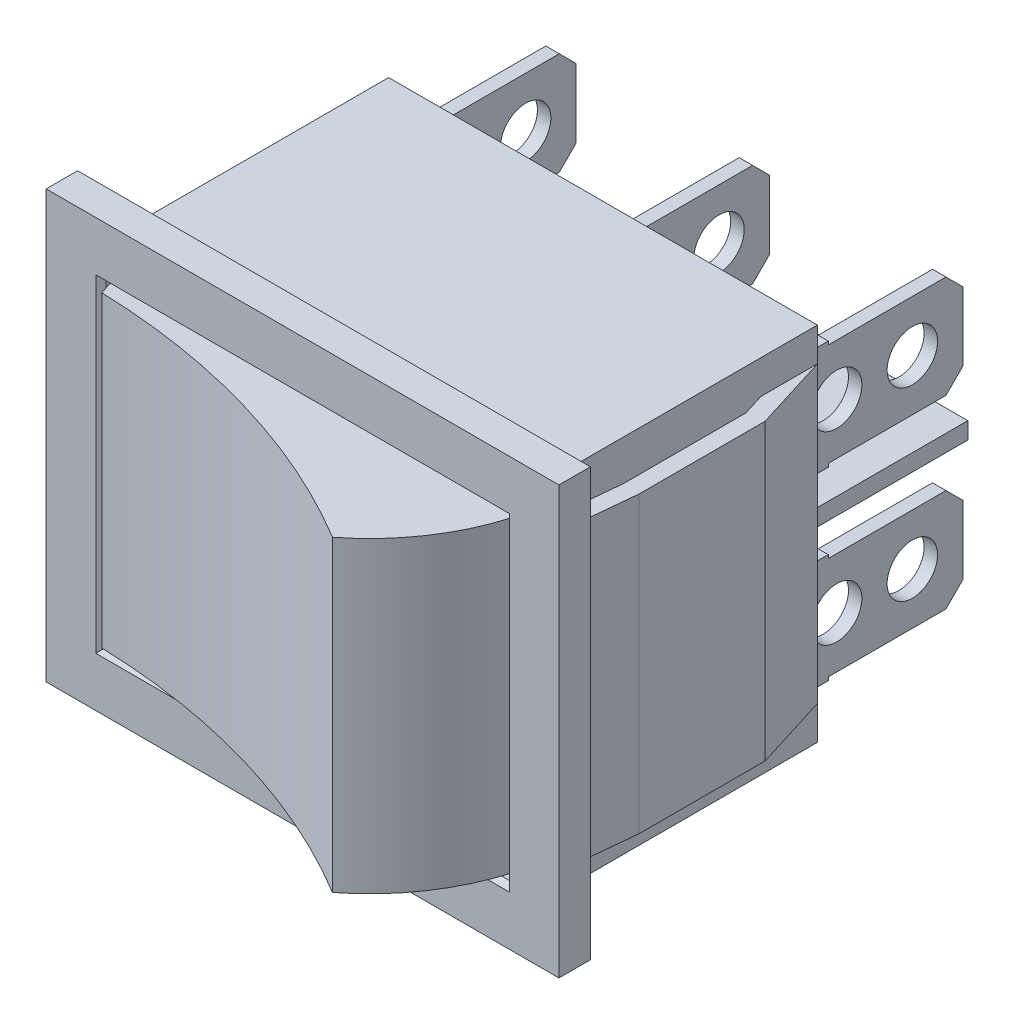
from build123d import *

# Parameters (mm, degrees)
SKETCH1_W                = 25.5
SKETCH1_H                = 21.5
BOSS_EXTRUDE1_DEPTH      = 16
SKETCH3_W                = 30.5
SKETCH3_H                = 25.4
BOSS_EXTRUDE3_DEPTH      = 1.87
SKETCH4_W                = 23.8
SKETCH4_H                = 1
BOSS_EXTRUDE4_DEPTH      = 9.8
SKETCH5_W                = 0.8
SKETCH5_H                = 6.5
BOSS_EXTRUDE5_DEPTH      = 9.5
SKETCH6_W                = 8
SKETCH6_H                = 0.2
CUT_EXTRUDE1_DEPTH       = 28.15
CHAMFER1_SIZE            = 1
SKETCH7_R                = 1.5
CUT_EXTRUDE2_DEPTH       = 28.15
CHAMFER1_OF_MIRROR1_SIZE = 1
BOSS_EXTRUDE6_START      = -2
BOSS_EXTRUDE6_DEPTH      = 17.5
SKETCH9_W                = 24
SKETCH9_H                = 18.9
CUT_EXTRUDE3_DEPTH       = 5
SKETCH10_R               = 12.5
BOSS_EXTRUDE7_DEPTH      = 9.15
SKETCH11_R               = 40
CUT_EXTRUDE4_DEPTH       = 13.7
CUT_EXTRUDE4_DEPTH_BACK  = 13.7
CHAMFER2_SIZE            = 0.3


with BuildPart() as part:
    # Sketch1 → Boss-Extrude1 (new body)
    with BuildSketch(Plane.XY):
        Rectangle(SKETCH1_W, SKETCH1_H)
    extrude(amount=BOSS_EXTRUDE1_DEPTH)

    # Sketch3 → Boss-Extrude3 (add)
    with BuildSketch(Plane.XY.offset(16)):
        Rectangle(SKETCH3_W, SKETCH3_H)
    extrude(amount=BOSS_EXTRUDE3_DEPTH)

    # Sketch4 → Boss-Extrude4 (add)
    with BuildSketch(Plane(origin=(0, 0, 0), x_dir=(-1, 0, 0), z_dir=(0, 0, -1))):
        Rectangle(SKETCH4_W, SKETCH4_H)
    extrude(amount=BOSS_EXTRUDE4_DEPTH)

    # Sketch5 → Boss-Extrude5 (add)
    with BuildSketch(Plane(origin=(0, 0, 0), x_dir=(-1, 0, 0), z_dir=(0, 0, -1))):
        with Locations((11.5, -5.5)):
            Rectangle(SKETCH5_W, SKETCH5_H)
        with Locations((0, -5.5)):
            Rectangle(SKETCH5_W, SKETCH5_H)
        with Locations((-11.5, -5.5)):
            Rectangle(SKETCH5_W, SKETCH5_H)
    boss_extrude5 = extrude(amount=BOSS_EXTRUDE5_DEPTH)

    # Sketch6 → Cut-Extrude1 (cut, through all)
    with BuildSketch(Plane(origin=(11.9, 0, 0), x_dir=(0, 0, -1), z_dir=(1, 0, 0))):
        with Locations((5.5, -2.35)):
            Rectangle(SKETCH6_W, SKETCH6_H)
        with Locations((5.5, -8.65)):
            Rectangle(SKETCH6_W, SKETCH6_H)
    cut_extrude1 = extrude(amount=-CUT_EXTRUDE1_DEPTH, mode=Mode.SUBTRACT)

    # Chamfer1
    chamfer1_edges = [part.edges().sort_by_distance(p)[0] for p in [
        (-11.5, -2.45, -9.5),
        (0, -2.45, -9.5),
        (-11.5, -8.55, -9.5),
        (0, -8.55, -9.5),
        (11.5, -8.55, -9.5),
        (11.5, -2.45, -9.5),
    ]]
    chamfer(chamfer1_edges, length=CHAMFER1_SIZE)

    # Sketch7 → Cut-Extrude2 (cut, through all)
    with BuildSketch(Plane(origin=(11.9, 0, 0), x_dir=(0, 0, -1), z_dir=(1, 0, 0))):
        with Locations((6.5, -5.5)):
            Circle(SKETCH7_R)
        with Locations((2, -5.5)):
            Circle(SKETCH7_R)
    cut_extrude2 = extrude(amount=-CUT_EXTRUDE2_DEPTH, mode=Mode.SUBTRACT)

    # Mirror1: Boss-Extrude5, Cut-Extrude1, Cut-Extrude2 across plane
    add(boss_extrude5.mirror(Plane(origin=(0, 0, 0), x_dir=(0, 0, 1), z_dir=(0, -1, 0))))
    add(cut_extrude1.mirror(Plane(origin=(0, 0, 0), x_dir=(0, 0, 1), z_dir=(0, -1, 0))), mode=Mode.SUBTRACT)
    add(cut_extrude2.mirror(Plane(origin=(0, 0, 0), x_dir=(0, 0, 1), z_dir=(0, -1, 0))), mode=Mode.SUBTRACT)

    # Chamfer1 of Mirror1
    chamfer1_of_mirror1_edges = [part.edges().sort_by_distance(p)[0] for p in [
        (-11.5, 2.45, -9.5),
        (0, 2.45, -9.5),
        (-11.5, 8.55, -9.5),
        (0, 8.55, -9.5),
        (11.5, 8.55, -9.5),
        (11.5, 2.45, -9.5),
    ]]
    chamfer(chamfer1_of_mirror1_edges, length=CHAMFER1_OF_MIRROR1_SIZE)

    # Sketch8 → Boss-Extrude6 (add)
    with BuildSketch(Plane(origin=(0, 10.75, 0), x_dir=(1, 0, 0), z_dir=(0, 1, 0)).offset(BOSS_EXTRUDE6_START)):
        Polygon((-12.75, 0), (-14.15, -4.5), (-14.15, -12), (-13.754867215, -16), (-12.75, -16), (-13.15, -11.95072831), (-13.15, -4.651963334), (-12.75, -3.366249048), align=None)
    boss_extrude6 = extrude(amount=-BOSS_EXTRUDE6_DEPTH)

    # Mirror2: Boss-Extrude6 across plane
    add(boss_extrude6.mirror(Plane.ZY))

    # Sketch9 → Cut-Extrude3 (cut)
    with BuildSketch(Plane.XY.offset(17.87)):
        Rectangle(SKETCH9_W, SKETCH9_H)
    extrude(amount=-CUT_EXTRUDE3_DEPTH, mode=Mode.SUBTRACT)

    # Sketch10 → Boss-Extrude7 (add, symmetric)
    with BuildSketch(Plane(origin=(0, 0, 0), x_dir=(-1, 0, 0), z_dir=(0, -1, 0))):
        with Locations((0, -13.87)):
            Circle(SKETCH10_R)
    extrude(amount=BOSS_EXTRUDE7_DEPTH, both=True)

    # Sketch11 → Cut-Extrude4 (cut, two sides)
    with BuildSketch(Plane(origin=(0, 0, 0), x_dir=(-1, 0, 0), z_dir=(0, -1, 0))) as cut_extrude4_sk:
        with Locations((13, -58)):
            Circle(SKETCH11_R)
    extrude(amount=CUT_EXTRUDE4_DEPTH, mode=Mode.SUBTRACT)
    extrude(cut_extrude4_sk.sketch, amount=-CUT_EXTRUDE4_DEPTH_BACK, mode=Mode.SUBTRACT)

    # Chamfer2
    chamfer2_edges = [part.edges().sort_by_distance(p)[0] for p in [
        (-12, 0, 17.87),
        (0, 9.45, 17.87),
        (0, -9.45, 17.87),
        (12, 0, 17.87),
    ]]
    chamfer(chamfer2_edges, length=CHAMFER2_SIZE)


solid = part.part
